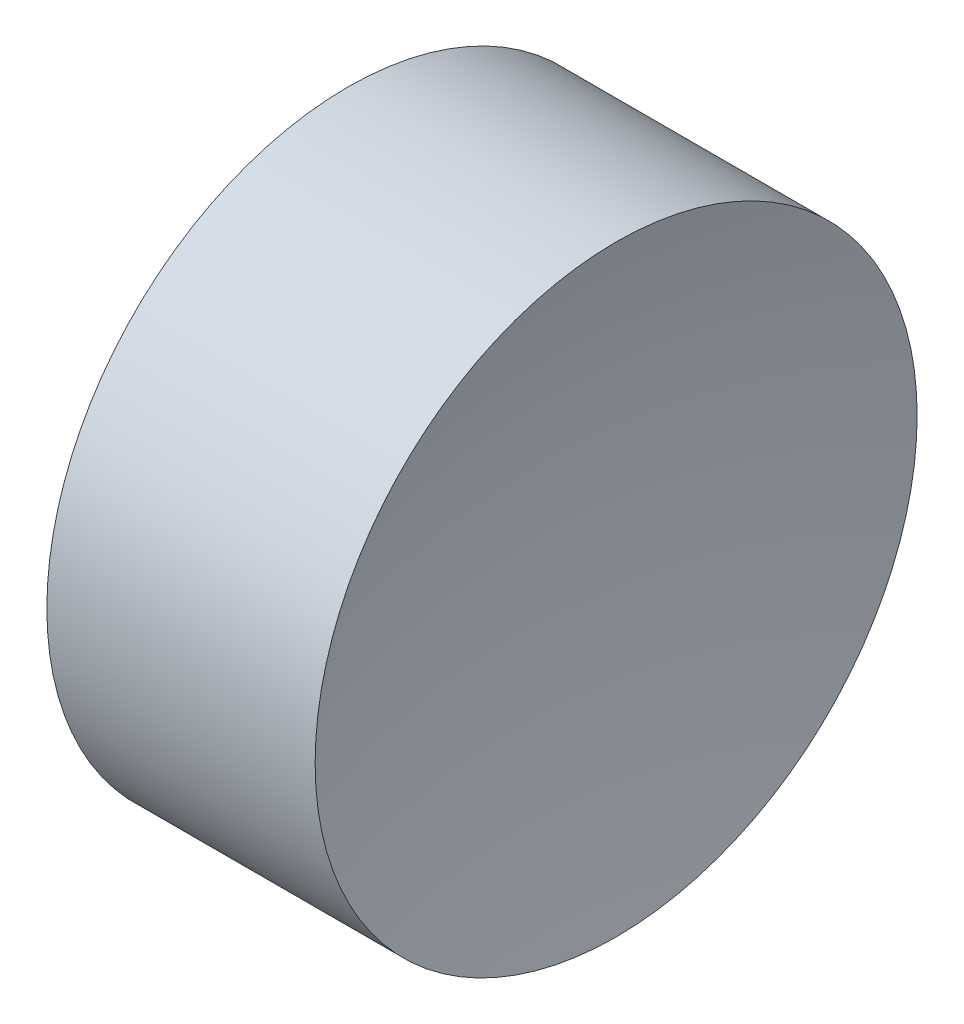
from build123d import *


with BuildPart() as part:
    # 草图1 → 旋转1 (revolve)
    with BuildSketch(Plane.XY, mode=Mode.PRIVATE) as revolve_1_sk:
        with BuildLine():
            Line((12.514118604, 6.522260287), (11.514118604, 6.522260287))
            ThreePointArc((11.514118604, 6.522260287), (11.47126748, 7.277109785), (11.343264701, 8.022260287))
            Line((11.343264701, 8.022260287), (12.014118604, 8.022260287))
            Line((12.014118604, 8.022260287), (12.680159624, 8.022260287))
            ThreePointArc((12.680159624, 8.022260287), (12.554578531, 7.276971489), (12.514118604, 6.522260287))
        make_face()
    revolve(revolve_1_sk.sketch.rotate(Axis((10.612465279, 6.522260287, 0), (1, 0, 0)), 90), axis=Axis((10.612465279, 6.522260287, 0), (1, 0, 0)))  # turned: the seam where the file's is


solid = part.part
